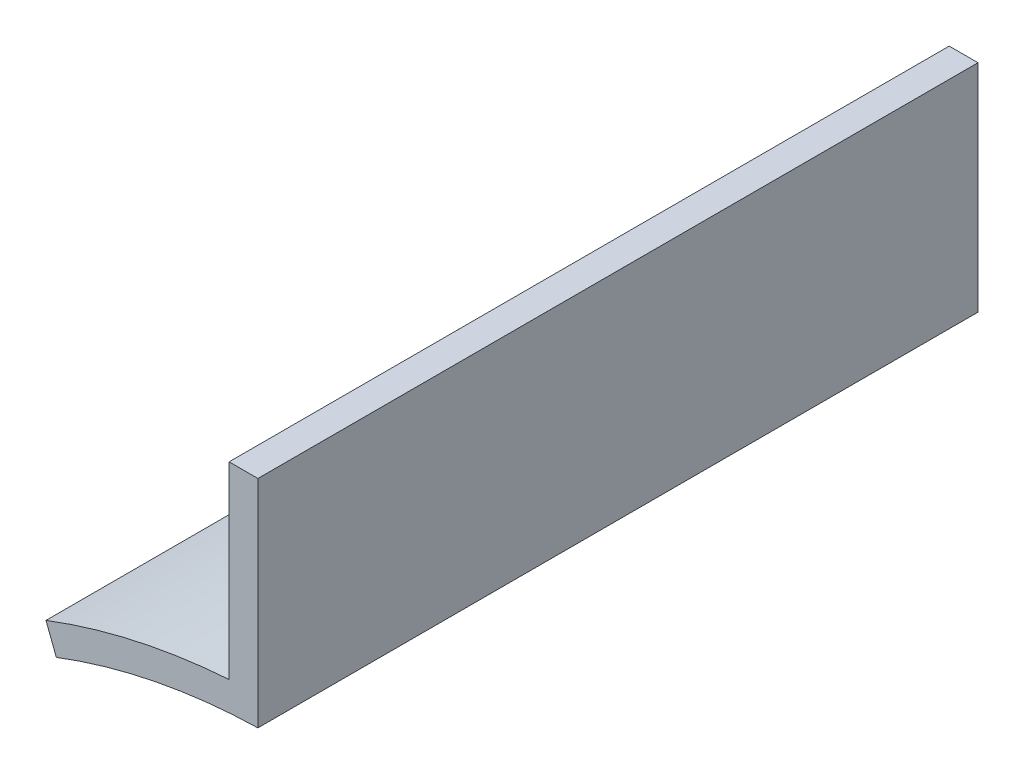
from build123d import *

# Parameters (mm, degrees)
BOSS_EXTRUDE1_DEPTH = 50


with BuildPart() as part:
    # Sketch1 → Boss-Extrude1 (new body)
    with BuildSketch(Plane.XY):
        with BuildLine():
            Line((-1, 41.98809355), (-1, 56.98809355))
            Line((-1, 56.98809355), (-3, 56.98809355))
            Line((-3, 56.98809355), (-3, 43.897608135))
            ThreePointArc((-3, 43.897608135), (-9.461252976, 42.97074228), (-15.714285714, 41.098190039))
            Line((-15.714285714, 41.098190039), (-15, 39.230090492))
            ThreePointArc((-15, 39.230090492), (-8.117982829, 41.207988968), (-1, 41.98809355))
        make_face()
    extrude(amount=BOSS_EXTRUDE1_DEPTH)


solid = part.part
